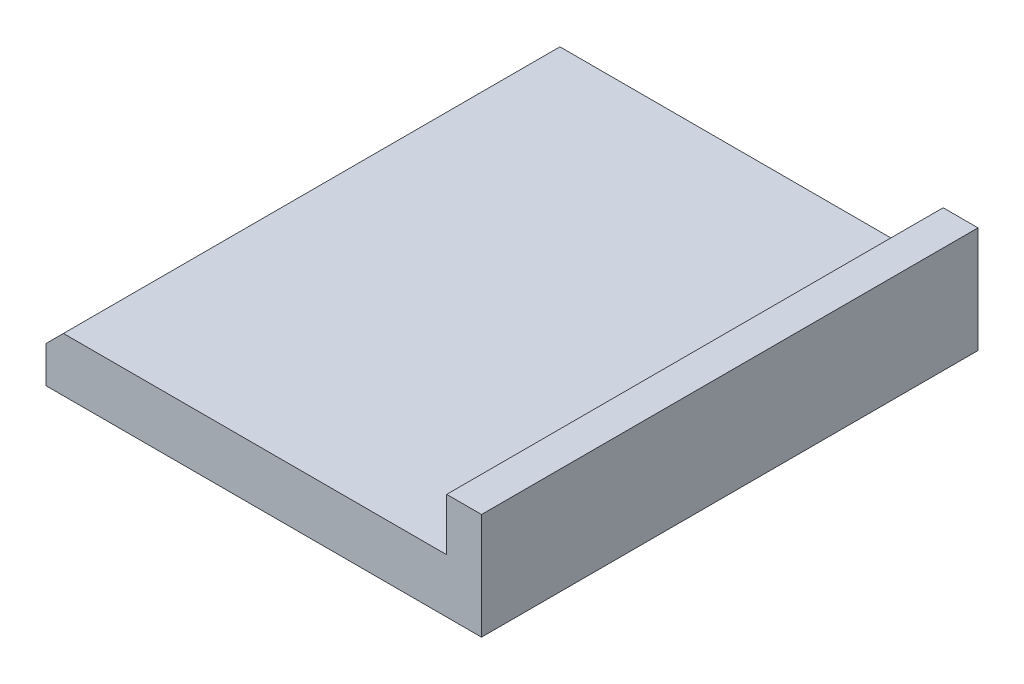
from build123d import *

# Parameters (mm, degrees)
SKETCH1_W           = 25
SKETCH1_H           = 28.5
BOSS_EXTRUDE1_DEPTH = 3.3
SKETCH2_W           = 2
SKETCH2_H           = 28.5
BOSS_EXTRUDE2_DEPTH = 3
CHAMFER1_SIZE       = 1
SKETCH3_R           = 21.891628128
CUT_EXTRUDE1_DEPTH  = 0.2


with BuildPart() as part:
    # Sketch1 → Boss-Extrude1 (new body)
    with BuildSketch(Plane(origin=(0, 0, 0), x_dir=(1, 0, 0), z_dir=(0, 1, 0))):
        with Locations((-3.305606618, -1.571691176)):
            Rectangle(SKETCH1_W, SKETCH1_H)
    extrude(amount=BOSS_EXTRUDE1_DEPTH)

    # Sketch2 → Boss-Extrude2 (add)
    with BuildSketch(Plane(origin=(0, 3.3, 0), x_dir=(1, 0, 0), z_dir=(0, 1, 0))):
        with Locations((8.194393382, -1.571691176)):
            Rectangle(SKETCH2_W, SKETCH2_H)
    extrude(amount=BOSS_EXTRUDE2_DEPTH)

    # Chamfer1
    chamfer1_edges = [part.edges().sort_by_distance(p)[0] for p in [
        (-15.805606618, 3.3, 1.571691176),
    ]]
    chamfer(chamfer1_edges, length=CHAMFER1_SIZE)

    # Sketch3 → Cut-Extrude1 (cut)
    with BuildSketch(Plane.XZ):
        with Locations((-2.847820653, 0)):
            Circle(SKETCH3_R)
    extrude(amount=-CUT_EXTRUDE1_DEPTH, mode=Mode.SUBTRACT)


solid = part.part
